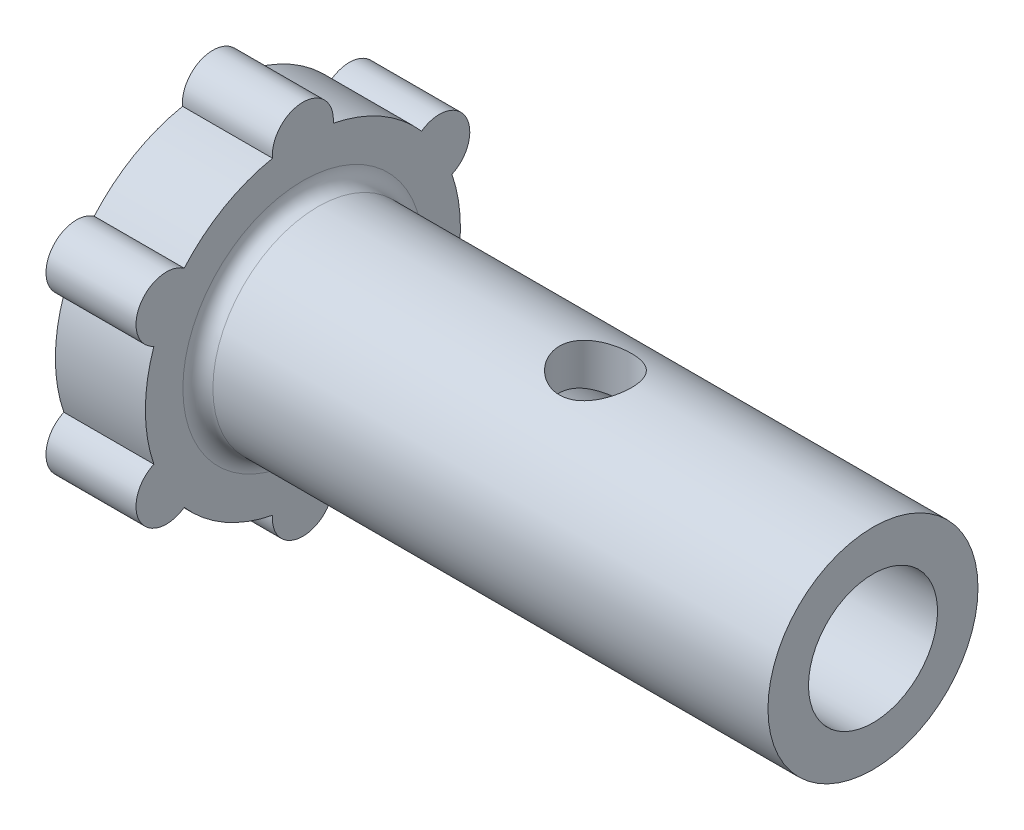
from build123d import *

# Parameters (mm, degrees)
FILLET1_R               = 0.5
FILLET2_R               = 0.2
SKETCH2_R               = 1.2
CUT_EXTRUDE1_DEPTH      = 6.25
CUT_EXTRUDE1_DEPTH_BACK = 6.25
BOSS_EXTRUDE1_DEPTH     = 3


with BuildPart() as part:
    # Sketch1 → Revolve1 (revolve)
    with BuildSketch(Plane.XY):
        Polygon((11, 2.15), (11, 3.5), (-8, 3.5), (-8, 5.25), (-11, 5.25), (-11, 3.5), (-9.524, 3.5), (-9.524, 2.15), align=None)
    revolve(axis=Axis((-11, 0, 0), (1, 0, 0)))

    # Fillet1
    fillet1_edges = [part.edges().sort_by_distance(p)[0] for p in [
        (-8, -3.5, 0),
    ]]
    fillet(fillet1_edges, radius=FILLET1_R)

    # Fillet2
    fillet2_edges = [part.edges().sort_by_distance(p)[0] for p in [
        (-9.524, -3.5, 0),
    ]]
    fillet(fillet2_edges, radius=FILLET2_R)

    # Sketch2 → Cut-Extrude1 (cut, two sides)
    with BuildSketch(Plane(origin=(0, 0, 0), x_dir=(1, 0, 0), z_dir=(0, 1, 0))) as cut_extrude1_sk:
        with Locations((1.75, 0)):
            Circle(SKETCH2_R)
    extrude(amount=CUT_EXTRUDE1_DEPTH, mode=Mode.SUBTRACT)
    extrude(cut_extrude1_sk.sketch, amount=-CUT_EXTRUDE1_DEPTH_BACK, mode=Mode.SUBTRACT)

    # Sketch3 → Boss-Extrude1 (add)
    with BuildSketch(Plane.ZY.offset(11)):
        with BuildLine():
            ThreePointArc((1.011232478, 5.151689905), (0, 6.266), (-1.011232478, 5.151689905))
            ThreePointArc((-1.011232478, 5.151689905), (0, 5.25), (1.011232478, 5.151689905))
        make_face()
        with BuildLine():
            ThreePointArc((4.967110569, 1.700091937), (5.42651518, 3.133), (3.955878091, 3.451597968))
            ThreePointArc((3.955878091, 3.451597968), (4.54663337, 2.625), (4.967110569, 1.700091937))
        make_face()
        with BuildLine():
            ThreePointArc((3.955878091, -3.451597968), (5.42651518, -3.133), (4.967110569, -1.700091937))
            ThreePointArc((4.967110569, -1.700091937), (4.54663337, -2.625), (3.955878091, -3.451597968))
        make_face()
        with BuildLine():
            ThreePointArc((-1.011232478, -5.151689905), (0, -6.266), (1.011232478, -5.151689905))
            ThreePointArc((1.011232478, -5.151689905), (0, -5.25), (-1.011232478, -5.151689905))
        make_face()
        with BuildLine():
            ThreePointArc((-4.967110569, -1.700091937), (-5.42651518, -3.133), (-3.955878091, -3.451597968))
            ThreePointArc((-3.955878091, -3.451597968), (-4.54663337, -2.625), (-4.967110569, -1.700091937))
        make_face()
        with BuildLine():
            ThreePointArc((-3.955878091, 3.451597968), (-5.42651518, 3.133), (-4.967110569, 1.700091937))
            ThreePointArc((-4.967110569, 1.700091937), (-4.54663337, 2.625), (-3.955878091, 3.451597968))
        make_face()
    extrude(amount=-BOSS_EXTRUDE1_DEPTH)


solid = part.part
